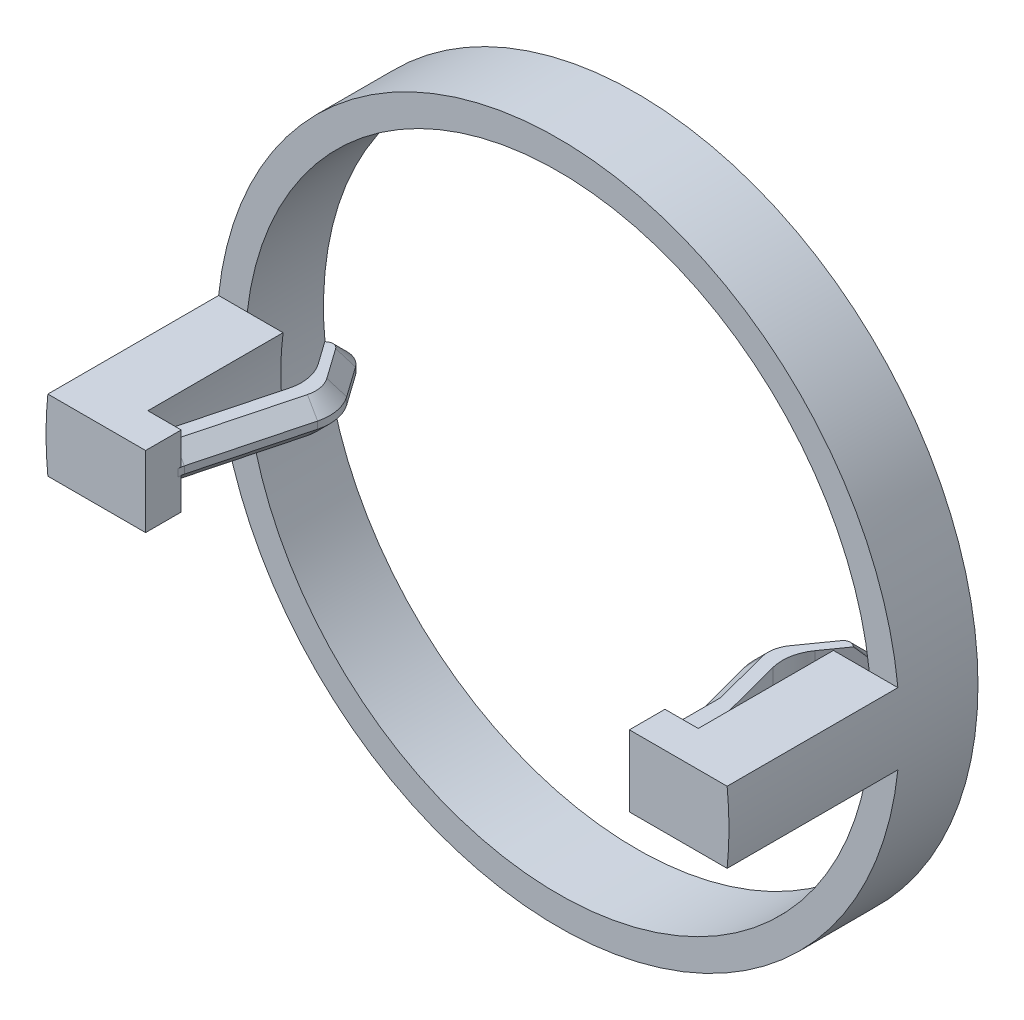
from build123d import *

# Parameters (mm, degrees)
IZIM1_R                          = 24
IZIM1_R_2                        = 22
Y_KSEKLIK_EKSTR_ZYON1_DEPTH      = 5.5
Y_KSEKLIK_EKSTR_ZYON6_DEPTH      = 1.25
Y_KSEKLIK_EKSTR_ZYON6_DEPTH_BACK = 1.25
PAH9_SIZE                        = 1
IZIM4_W                          = 12
IZIM4_H                          = 5
Y_KSEKLIK_EKSTR_ZYON7_DEPTH      = 4.5
IZIM5_W                          = 12
IZIM5_H                          = 5
Y_KSEKLIK_EKSTR_ZYON8_DEPTH      = 4.5
IZIM6_R                          = 29.704861037
IZIM6_R_2                        = 24
KES_EKSTR_ZYON1_DEPTH            = 34.5
Y_KSEKLIK_EKSTR_ZYON13_DEPTH     = 12
IZIM9_W                          = 4.857492994
IZIM9_H                          = 5
Y_KSEKLIK_EKSTR_ZYON15_DEPTH     = 2.5


with BuildPart() as part:
    # izim1 → Y_kseklik-Ekstr_zyon1 (new body)
    with BuildSketch(Plane.XY):
        Circle(IZIM1_R)
        Circle(IZIM1_R_2, mode=Mode.SUBTRACT)
    extrude(amount=Y_KSEKLIK_EKSTR_ZYON1_DEPTH)

    # izim3 → Y_kseklik-Ekstr_zyon6 (add, two sides)
    with BuildSketch(Plane(origin=(0, 0, 0), x_dir=(1, 0, 0), z_dir=(0, 1, 0))) as y_kseklik_ekstr_zyon6_sk:
        with BuildLine():
            Line((-24, -5.5), (-22, -5.5))
            Line((-22, -5.5), (-22, -14))
            ThreePointArc((-22, -14), (-21.707106781, -14.707106781), (-21, -15))
            Line((-21, -15), (-19.999172426, -15))
            ThreePointArc((-19.999172426, -15), (-19.204818142, -14.729361443), (-18.740932642, -14.030037341))
            Line((-18.740932642, -14.030037341), (-16.999602498, -7.412982791))
            ThreePointArc((-16.999602498, -7.412982791), (-16.949017228, -6.113943068), (-17.452736756, -4.915473333))
            Line((-17.452736756, -4.915473333), (-19.156539239, -2.510058329))
            Line((-19.156539239, -2.510058329), (-19.048774697, -2.433726597))
            ThreePointArc((-19.048774697, -2.433726597), (-17.929301656, -2.179168952), (-16.95771524, -2.790756494))
            Line((-16.95771524, -2.790756494), (-15.452736756, -4.915473333))
            ThreePointArc((-15.452736756, -4.915473333), (-14.949017228, -6.113943068), (-14.999602498, -7.412982791))
            Line((-14.999602498, -7.412982791), (-16.950611806, -14.826818162))
            ThreePointArc((-16.950611806, -14.826818162), (-16.987601712, -15.016097347), (-17, -15.208558111))
            Line((-17, -15.208558111), (-17, -17.5))
            Line((-17, -17.5), (-24, -17.5))
            Line((-24, -17.5), (-24, -5.5))
        make_face()
        with BuildLine():
            Line((19.156539239, -2.510058329), (19.048774697, -2.433726597))
            ThreePointArc((19.048774697, -2.433726597), (17.929301656, -2.179168952), (16.95771524, -2.790756494))
            Line((16.95771524, -2.790756494), (15.452736756, -4.915473333))
            ThreePointArc((15.452736756, -4.915473333), (14.949017228, -6.113943068), (14.999602498, -7.412982791))
            Line((14.999602498, -7.412982791), (17, -15.014493299))
            Line((17, -15.014493299), (17, -17.5))
            Line((17, -17.5), (24, -17.5))
            Line((24, -17.5), (24, -5.5))
            Line((24, -5.5), (22, -5.5))
            Line((22, -5.5), (22, -14))
            ThreePointArc((22, -14), (21.707106781, -14.707106781), (21, -15))
            Line((21, -15), (19.999172426, -15))
            ThreePointArc((19.999172426, -15), (19.204818142, -14.729361443), (18.740932642, -14.030037341))
            Line((18.740932642, -14.030037341), (16.999602498, -7.412982791))
            ThreePointArc((16.999602498, -7.412982791), (16.949017228, -6.113943068), (17.452736756, -4.915473333))
            Line((17.452736756, -4.915473333), (19.156539239, -2.510058329))
        make_face()
    extrude(amount=Y_KSEKLIK_EKSTR_ZYON6_DEPTH)
    extrude(y_kseklik_ekstr_zyon6_sk.sketch, amount=-Y_KSEKLIK_EKSTR_ZYON6_DEPTH_BACK)

    # Pah9
    pah9_edges = [part.edges().sort_by_distance(p)[0] for p in [
        (-19.102656968, -1.25, 2.471892463),
        (-17.929301656, -1.25, 2.179168952),
        (-16.205225998, -1.25, 3.853114913),
        (-14.949017228, -1.25, 6.113943068),
        (-15.975107152, -1.25, 11.119900476),
        (-16.987601712, -1.25, 15.016097347),
        (-17, -1.25, 16.354279055),
        (-17, 1.25, 16.354279055),
        (-16.987601712, 1.25, 15.016097347),
        (-15.975107152, 1.25, 11.119900476),
        (-14.949017228, 1.25, 6.113943068),
        (-16.205225998, 1.25, 3.853114913),
        (-17.929301656, 1.25, 2.179168952),
        (-19.102656968, 1.25, 2.471892463),
        (15.999801249, -1.25, 11.213738045),
        (14.949017228, -1.25, 6.113943068),
        (16.205225998, -1.25, 3.853114913),
        (17.929301656, -1.25, 2.179168952),
        (19.102656968, -1.25, 2.471892463),
        (19.102656968, 1.25, 2.471892463),
        (17.929301656, 1.25, 2.179168952),
        (16.205225998, 1.25, 3.853114913),
        (14.949017228, 1.25, 6.113943068),
        (15.999801249, 1.25, 11.213738045),
    ]]
    chamfer(pah9_edges, length=PAH9_SIZE)

    # izim4 → Y_kseklik-Ekstr_zyon7 (add)
    with BuildSketch(Plane(origin=(24, 0, 0), x_dir=(0, 0, -1), z_dir=(1, 0, 0))):
        with Locations((-11.5, 0)):
            Rectangle(IZIM4_W, IZIM4_H)
    extrude(amount=-Y_KSEKLIK_EKSTR_ZYON7_DEPTH)

    # izim5 → Y_kseklik-Ekstr_zyon8 (add)
    with BuildSketch(Plane.ZY.offset(24)):
        with Locations((11.5, 0)):
            Rectangle(IZIM5_W, IZIM5_H)
    extrude(amount=-Y_KSEKLIK_EKSTR_ZYON8_DEPTH)

    # izim6 → Kes-Ekstr_zyon1 (cut)
    with BuildSketch(Plane.XY.offset(17.5)):
        Circle(IZIM6_R)
        Circle(IZIM6_R_2, mode=Mode.SUBTRACT)
    extrude(amount=-KES_EKSTR_ZYON1_DEPTH, mode=Mode.SUBTRACT)

    # izim7 → Y_kseklik-Ekstr_zyon13 (add)
    with BuildSketch(Plane.XY.offset(17.5)):
        with BuildLine():
            Line((-19.459894655, -1.25), (-19.5, -1.25))
            Line((-19.5, -1.25), (-19.5, -2.5))
            Line((-19.5, -2.5), (-19.339079606, -2.5))
            ThreePointArc((-19.339079606, -2.5), (-19.40955244, -1.875972833), (-19.459894655, -1.25))
        make_face()
        with BuildLine():
            ThreePointArc((-19.459894655, -1.25), (-19.489971085, -0.625321608), (-19.5, -5e-09))
            Line((-19.5, -5e-09), (-19.5, -1.25))
            Line((-19.5, -1.25), (-19.459894655, -1.25))
        make_face()
        with BuildLine():
            Line((-19.339079606, 2.5), (-19.5, 2.5))
            Line((-19.5, 2.5), (-19.5, 1.25))
            Line((-19.5, 1.25), (-19.459894655, 1.25))
            ThreePointArc((-19.459894655, 1.25), (-19.40955244, 1.875972833), (-19.339079606, 2.5))
        make_face()
        with BuildLine():
            Line((-19.459894655, 1.25), (-19.5, 1.25))
            Line((-19.5, 1.25), (-19.5, -5e-09))
            ThreePointArc((-19.5, -5e-09), (-19.489971085, 0.625321602), (-19.459894655, 1.25))
        make_face()
        with BuildLine():
            Line((19.339079606, -2.5), (19.5, -2.5))
            Line((19.5, -2.5), (19.5, -6e-08))
            ThreePointArc((19.5, -6e-08), (19.459728315, -1.252586891), (19.339079606, -2.5))
        make_face()
        with BuildLine():
            ThreePointArc((19.339079606, 2.5), (19.459728319, 1.252586831), (19.5, -6e-08))
            Line((19.5, -6e-08), (19.5, 2.5))
            Line((19.5, 2.5), (19.339079606, 2.5))
        make_face()
    extrude(amount=-Y_KSEKLIK_EKSTR_ZYON13_DEPTH)

    # izim9 → Y_kseklik-Ekstr_zyon15 (add)
    with BuildSketch(Plane.XY.offset(17.5)):
        with Locations((-19.428746497, 0)):
            Rectangle(IZIM9_W, IZIM9_H)
        with Locations((19.428746497, 0)):
            Rectangle(IZIM9_W, IZIM9_H)
    extrude(amount=-Y_KSEKLIK_EKSTR_ZYON15_DEPTH)


solid = part.part
